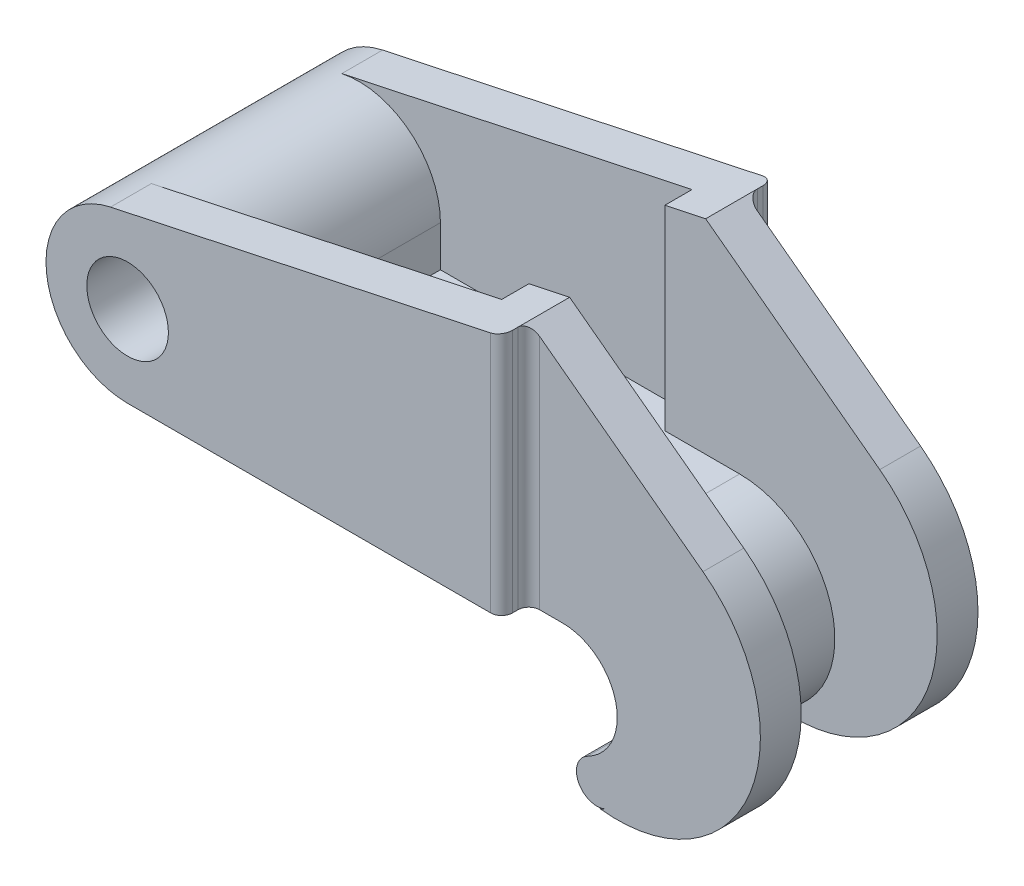
from build123d import *

# Parameters (mm, degrees)
SKETCH1_R            = 9.525
BOSS_EXTRUDE1_DEPTH  = 15.875
SKETCH1_3_R          = 9.525
BOSS_EXTRUDE2_DEPTH  = 22.225
BOSS_EXTRUDE6_START  = 22.225
SKETCH1_7_R          = 9.525
BOSS_EXTRUDE6_DEPTH  = 9.525
BOSS_EXTRUDE8_START  = 15.875
BOSS_EXTRUDE8_DEPTH  = 9.525
BOSS_EXTRUDE10_START = 25.4
BOSS_EXTRUDE10_DEPTH = 9.525
CUT_EXTRUDE1_DEPTH   = 153.513472698
FILLET1_R            = 2.54


with BuildPart() as part:
    # Sketch1 → Boss-Extrude1 (new, symmetric)
    with BuildSketch(Plane.XY):
        with BuildLine():
            Line((0, -19.05), (95.25, -19.05))
            ThreePointArc((95.25, -19.05), (107.598173959, -28.781397654), (101.022727273, -43.062188994))
            ThreePointArc((101.022727273, -43.062188994), (98.945429127, -49.469032594), (105.352272727, -51.546330739))
            ThreePointArc((105.352272727, -51.546330739), (116.859304428, -26.554945895), (95.25, -9.525))
            Line((95.25, -9.525), (19.05, -9.525))
            Line((19.05, -9.525), (19.05, 0))
            ThreePointArc((19.05, 0), (-13.470384182, 13.470384182), (0, -19.05))
        make_face()
        Circle(SKETCH1_R, mode=Mode.SUBTRACT)
    extrude(amount=BOSS_EXTRUDE1_DEPTH, both=True)

    # Sketch1_3 → Boss-Extrude2 (add, symmetric)
    with BuildSketch(Plane.XY):
        with BuildLine():
            Line((0, -19.05), (77.7875, -19.05))
            Line((77.7875, -19.05), (77.7875, -9.525))
            Line((77.7875, -9.525), (19.05, -9.525))
            Line((19.05, -9.525), (19.05, 0))
            ThreePointArc((19.05, 0), (-13.470384182, 13.470384182), (0, -19.05))
        make_face()
        Circle(SKETCH1_3_R, mode=Mode.SUBTRACT)
    extrude(amount=BOSS_EXTRUDE2_DEPTH, both=True)

    # Sketch1_7 → Boss-Extrude6 (add)
    with BuildSketch(Plane.XY.offset(BOSS_EXTRUDE6_START)):
        with BuildLine():
            ThreePointArc((-3.973521059, 18.63098576), (-18.944956832, -1.997776423), (0, -19.05))
            Line((0, -19.05), (87.3125, -19.05))
            Line((87.3125, -19.05), (87.3125, 38.1))
            Line((87.3125, 38.1), (-3.973521059, 18.63098576))
        make_face()
        Circle(SKETCH1_7_R, mode=Mode.SUBTRACT)
    boss_extrude6 = extrude(amount=BOSS_EXTRUDE6_DEPTH)

    # Sketch1_9 → Boss-Extrude8 (add)
    with BuildSketch(Plane.XY.offset(BOSS_EXTRUDE8_START)):
        Polygon((77.7875, -19.05), (87.3125, -19.05), (87.3125, 38.1), (77.7875, 36.068556867), align=None)
    boss_extrude8 = extrude(amount=BOSS_EXTRUDE8_DEPTH)

    # Sketch1_10 → Boss-Extrude10 (add)
    with BuildSketch(Plane.XY.offset(BOSS_EXTRUDE10_START)):
        with BuildLine():
            Line((87.3125, -19.05), (95.25, -19.05))
            ThreePointArc((95.25, -19.05), (107.598173959, -28.781397654), (101.022727273, -43.062188994))
            ThreePointArc((101.022727273, -43.062188994), (98.945429127, -49.469032594), (105.352272727, -51.546330739))
            ThreePointArc((105.352272727, -51.546330739), (104.635512697, -51.896036246), (103.906667348, -52.219800571))
            ThreePointArc((103.906667348, -52.219800571), (138.961341357, -31.495116154), (127.958197617, 7.712963905))
            Line((127.958197617, 7.712963905), (87.3125, 38.1))
            Line((87.3125, 38.1), (87.3125, -19.05))
        make_face()
    boss_extrude10 = extrude(amount=-BOSS_EXTRUDE10_DEPTH)

    # Mirror1: Boss-Extrude6, Boss-Extrude8, Boss-Extrude10 across plane
    add(boss_extrude6.mirror(Plane.XY))
    add(boss_extrude8.mirror(Plane.XY))
    add(boss_extrude10.mirror(Plane.XY))

    # Sketch2 → Cut-Extrude1 (cut, through all)
    with BuildSketch(Plane(origin=(0, -9.525, 0), x_dir=(1, 0, 0), z_dir=(0, 1, 0))):
        with BuildLine():
            Line((28.575, -15.875), (43.269345299, -15.875))
            ThreePointArc((43.269345299, -15.875), (44.92702794, -15.766349739), (46.556347172, -15.442257994))
            Line((46.556347172, -15.442257994), (81.296623537, -6.133628997))
            ThreePointArc((81.296623537, -6.133628997), (86.003122601, 0), (81.296623537, 6.133628997))
            Line((81.296623537, 6.133628997), (46.556347172, 15.442257994))
            ThreePointArc((46.556347172, 15.442257994), (44.92702794, 15.766349739), (43.269345299, 15.875))
            Line((43.269345299, 15.875), (28.575, 15.875))
            Line((28.575, 15.875), (28.575, -15.875))
        make_face()
    extrude(amount=-CUT_EXTRUDE1_DEPTH, mode=Mode.SUBTRACT)

    # Fillet1
    fillet1_edges = [part.edges().sort_by_distance(p)[0] for p in [
        (87.3125, 9.525, -31.75),
        (87.3125, 9.525, -25.4),
        (87.3125, 9.525, 31.75),
        (87.3125, 9.525, 25.4),
    ]]
    fillet(fillet1_edges, radius=FILLET1_R)


solid = part.part
